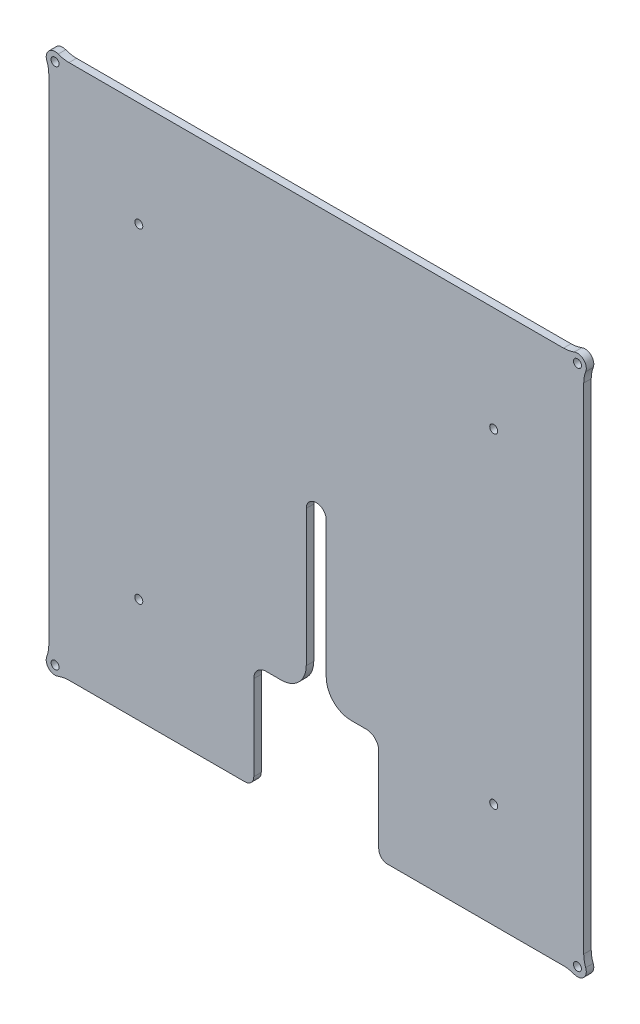
from build123d import *

# Parameters (mm, degrees)
SKETCH1_R           = 1.6
BOSS_EXTRUDE1_DEPTH = 3
SKETCH3_R           = 1.6
CUT_EXTRUDE2_DEPTH  = 4
CUT_EXTRUDE5_DEPTH  = 4
FILLET1_R           = 3.54


with BuildPart() as part:
    # Sketch1 → Boss-Extrude1 (new body)
    with BuildSketch(Plane.XY):
        with BuildLine():
            Line((-107, 98.923010333), (-107, -98.923010333))
            ThreePointArc((-107, -98.923010333), (-107.201661971, -101.11372249), (-107.799869959, -103.230804092))
            ThreePointArc((-107.799869959, -103.230804092), (-107, -107), (-103.230804092, -107.799869959))
            ThreePointArc((-103.230804092, -107.799869959), (-101.11372249, -107.201661971), (-98.923010333, -107))
            Line((-98.923010333, -107), (-43, -107))
            Line((-43, -107), (43, -107))
            Line((43, -107), (98.923010333, -107))
            ThreePointArc((98.923010333, -107), (101.11372249, -107.201661971), (103.230804092, -107.799869959))
            ThreePointArc((103.230804092, -107.799869959), (107, -107), (107.799869959, -103.230804092))
            ThreePointArc((107.799869959, -103.230804092), (107.201661971, -101.11372249), (107, -98.923010333))
            Line((107, -98.923010333), (107, 98.923010333))
            ThreePointArc((107, 98.923010333), (107.201661971, 101.11372249), (107.799869959, 103.230804092))
            ThreePointArc((107.799869959, 103.230804092), (107, 107), (103.230804092, 107.799869959))
            ThreePointArc((103.230804092, 107.799869959), (101.11372249, 107.201661971), (98.923010333, 107))
            Line((98.923010333, 107), (-98.923010333, 107))
            ThreePointArc((-98.923010333, 107), (-101.11372249, 107.201661971), (-103.230804092, 107.799869959))
            ThreePointArc((-103.230804092, 107.799869959), (-107, 107), (-107.799869959, 103.230804092))
            ThreePointArc((-107.799869959, 103.230804092), (-107.201661971, 101.11372249), (-107, 98.923010333))
        make_face()
        with Locations((-104.5, -104.5)):
            Circle(SKETCH1_R, mode=Mode.SUBTRACT)
        with Locations((-104.5, 104.5)):
            Circle(SKETCH1_R, mode=Mode.SUBTRACT)
        with Locations((104.5, 104.5)):
            Circle(SKETCH1_R, mode=Mode.SUBTRACT)
        with Locations((104.5, -104.5)):
            Circle(SKETCH1_R, mode=Mode.SUBTRACT)
    extrude(amount=BOSS_EXTRUDE1_DEPTH)

    # Sketch3 → Cut-Extrude2 (cut, through all)
    with BuildSketch(Plane.XY.offset(3)):
        with Locations((-71, 65)):
            Circle(SKETCH3_R)
        with Locations((71, 65)):
            Circle(SKETCH3_R)
        with Locations((71, -65)):
            Circle(SKETCH3_R)
        with Locations((-71, -65)):
            Circle(SKETCH3_R)
    extrude(amount=-CUT_EXTRUDE2_DEPTH, mode=Mode.SUBTRACT)

    # Sketch5 → Cut-Extrude5 (cut, through all)
    with BuildSketch(Plane.XY):
        with BuildLine():
            Line((-25, -107), (25, -107))
            Line((25, -107), (25, -69.5))
            ThreePointArc((25, -69.5), (23.535533906, -65.964466094), (20, -64.5))
            Line((20, -64.5), (14, -64.5))
            ThreePointArc((14, -64.5), (6.928932188, -61.571067812), (4, -54.5))
            Line((4, -54.5), (4, 0))
            ThreePointArc((4, 0), (0, 4), (-4, 0))
            Line((-4, 0), (-4, -54.5))
            ThreePointArc((-4, -54.5), (-6.928932188, -61.571067812), (-14, -64.5))
            Line((-14, -64.5), (-20, -64.5))
            ThreePointArc((-20, -64.5), (-23.535533906, -65.964466094), (-25, -69.5))
            Line((-25, -69.5), (-25, -107))
        make_face()
    extrude(amount=CUT_EXTRUDE5_DEPTH, mode=Mode.SUBTRACT)

    # Fillet1
    fillet1_edges = [part.edges().sort_by_distance(p)[0] for p in [
        (-25, -107, 1.5),
        (25, -107, 1.5),
    ]]
    fillet(fillet1_edges, radius=FILLET1_R)


solid = part.part
